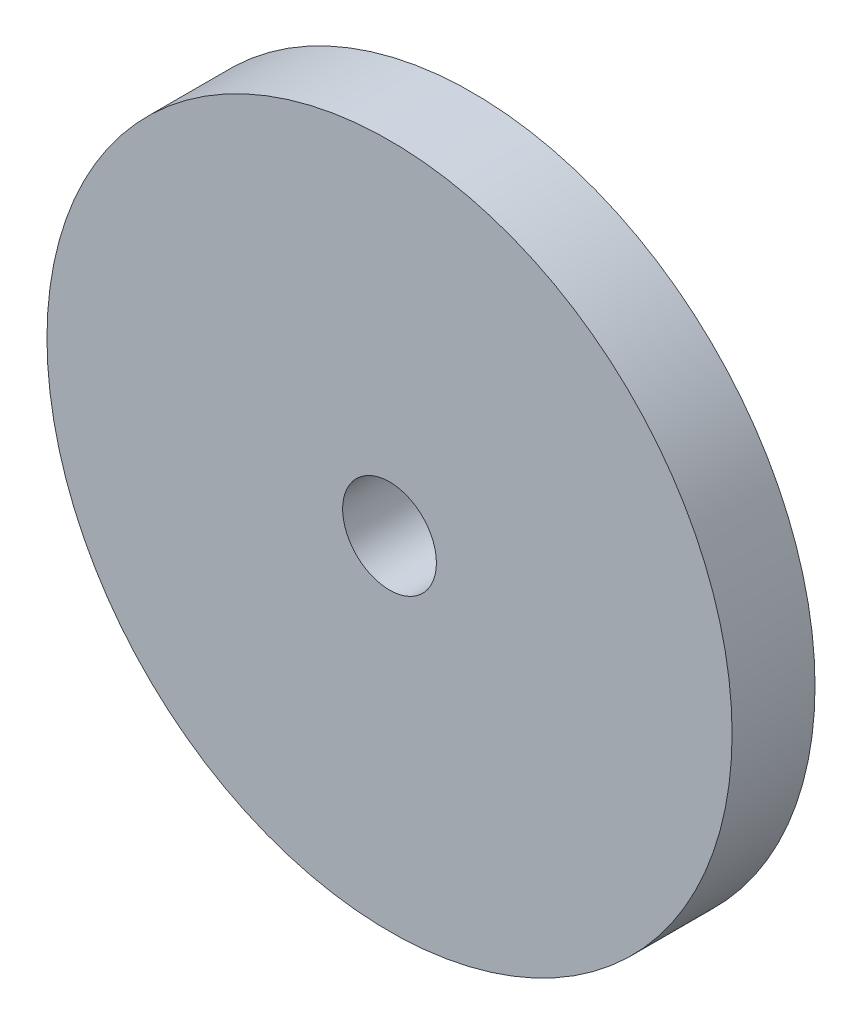
from build123d import *

# Parameters (mm, degrees)
SKICA1_R                = 9.5
SKICA1_R_2              = 1.3
P_IDAT_VYSUNUT_M1_DEPTH = 2.3


with BuildPart() as part:
    # Skica1 → Přidat vysunutím1 (new body)
    with BuildSketch(Plane.XY):
        Circle(SKICA1_R)
        Circle(SKICA1_R_2, mode=Mode.SUBTRACT)
    extrude(amount=P_IDAT_VYSUNUT_M1_DEPTH)


solid = part.part
